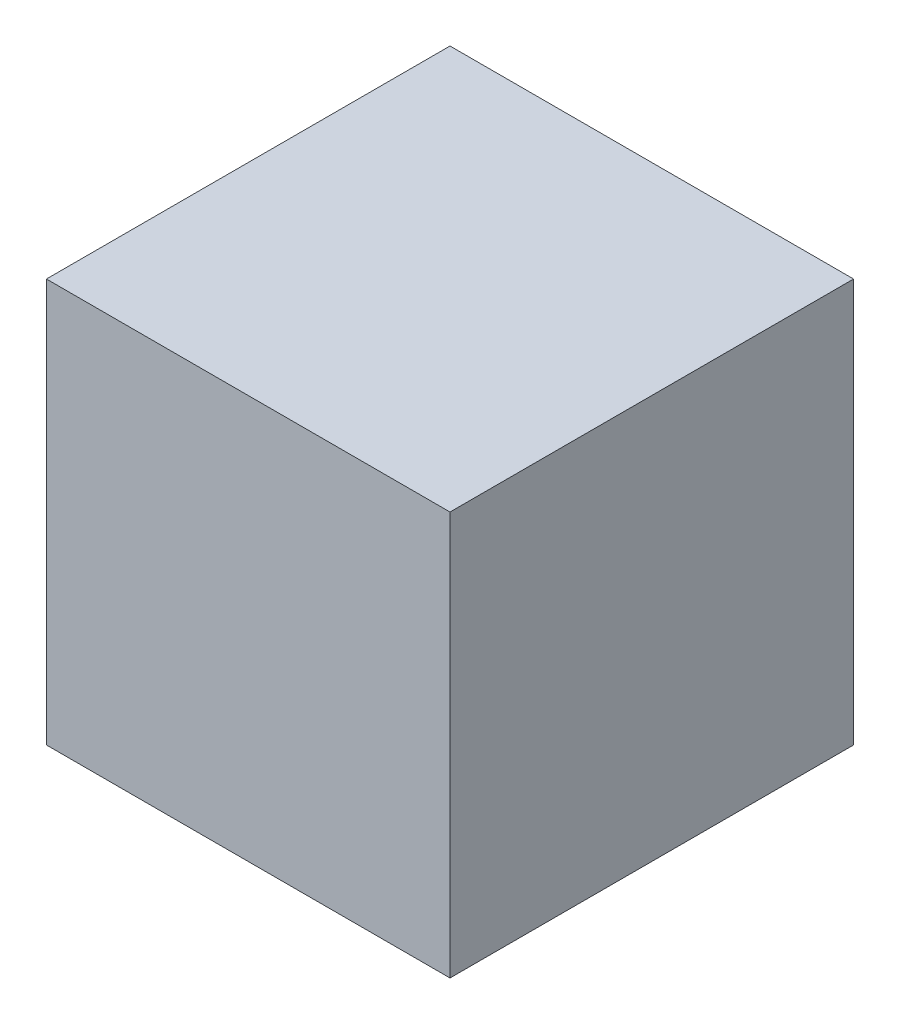
from build123d import *

# Parameters (mm, degrees)
SKETCH1_W           = 50
SKETCH1_H           = 50
BOSS_EXTRUDE1_DEPTH = 50


with BuildPart() as part:
    # Sketch1 → Boss-Extrude1 (new body)
    with BuildSketch(Plane.XY):
        with Locations((-25, 25)):
            Rectangle(SKETCH1_W, SKETCH1_H)
    extrude(amount=BOSS_EXTRUDE1_DEPTH)


solid = part.part
